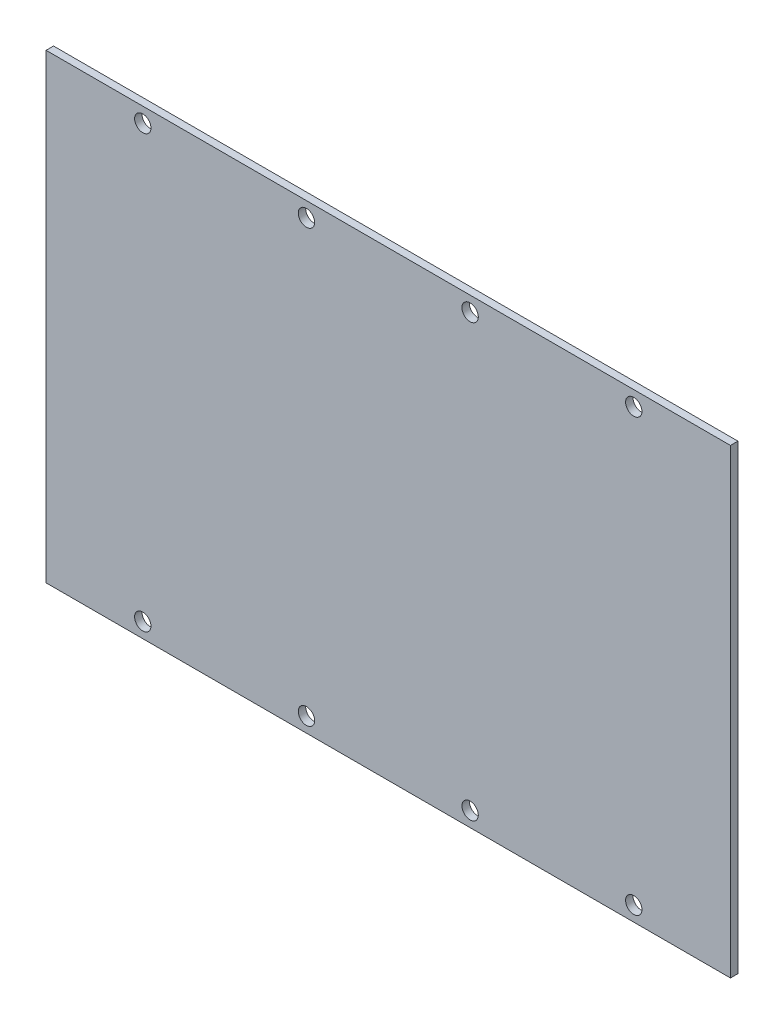
from build123d import *

# Parameters (mm, degrees)
SKETCH1_W                  = 92
SKETCH1_H                  = 62
BOSS_EXTRUDE1_DEPTH        = 1
F_2_2_2_2_DIAMETER_HOLE2_D = 2.2


with BuildPart() as part:
    # Sketch1 → Boss-Extrude1 (new body)
    with BuildSketch(Plane.XY):
        with Locations((46, -31)):
            Rectangle(SKETCH1_W, SKETCH1_H)
    extrude(amount=-BOSS_EXTRUDE1_DEPTH)

    # Ø2.2 (2.2) Diameter Hole2 (through all)
    with Locations(Plane(origin=(0, 0, -1), x_dir=(-1, 0, 0), z_dir=(0, 0, -1))):
        with Locations((-79, -2), (-57, -2), (-35, -2), (-13, -2), (-13, -60), (-35, -60), (-57, -60), (-79, -60)):
            Hole(F_2_2_2_2_DIAMETER_HOLE2_D / 2)


solid = part.part
